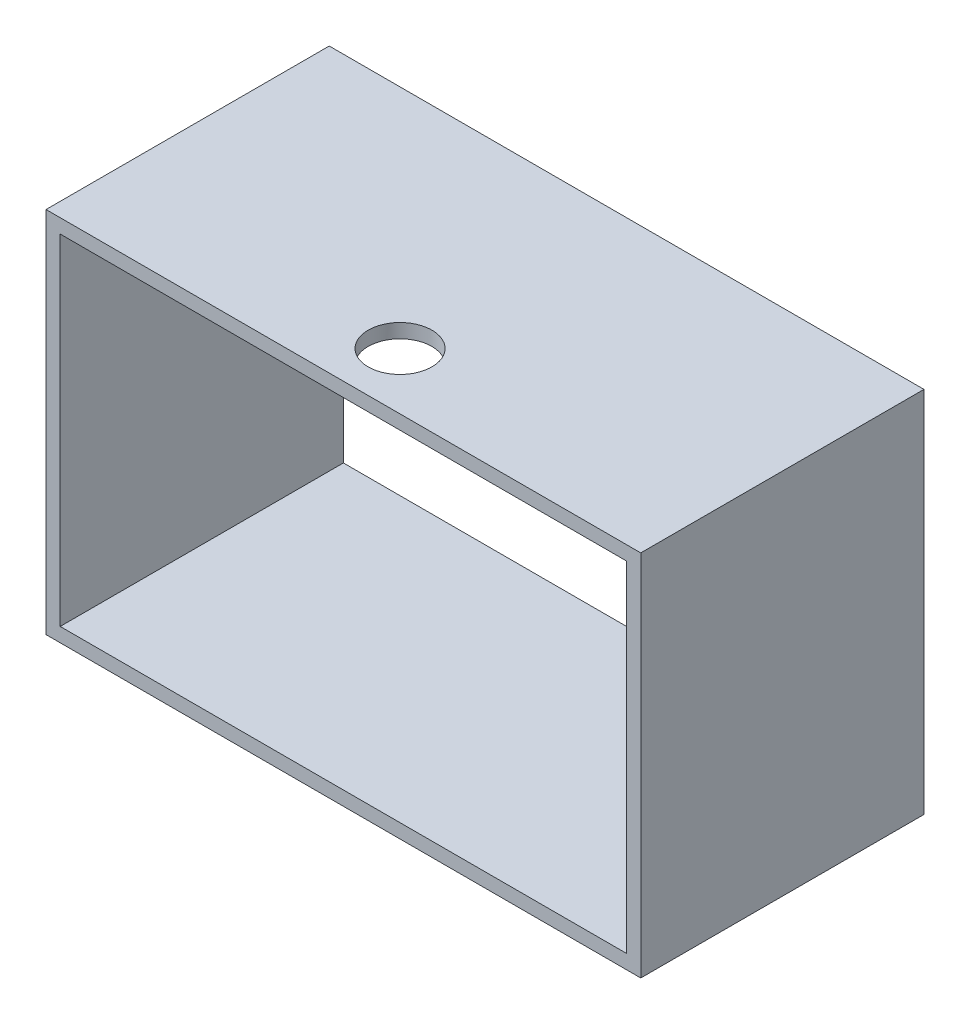
from build123d import *

# Parameters (mm, degrees)
SKETCH1_W           = 266.7
SKETCH1_H           = 165.1
SKETCH1_W_2         = 254
SKETCH1_H_2         = 152.4
BOSS_EXTRUDE1_DEPTH = 215.9
SKETCH4_W           = 88.9
SKETCH4_H           = 165.1
CUT_EXTRUDE2_DEPTH  = 267.7
CUT_EXTRUDE3_REACH  = 167.1
SKETCH5_R           = 14.2875


with BuildPart() as part:
    # Sketch1 → Boss-Extrude1 (new body)
    with BuildSketch(Plane.XY):
        with Locations((133.35, 82.55)):
            Rectangle(SKETCH1_W, SKETCH1_H)
        with Locations((133.35, 82.55)):
            Rectangle(SKETCH1_W_2, SKETCH1_H_2, mode=Mode.SUBTRACT)
    extrude(amount=BOSS_EXTRUDE1_DEPTH)

    # Sketch4 → Cut-Extrude2 (cut, through all)
    with BuildSketch(Plane(origin=(266.7, 0, 0), x_dir=(0, 0, -1), z_dir=(1, 0, 0))):
        with Locations((-171.45, 82.55)):
            Rectangle(SKETCH4_W, SKETCH4_H)
    extrude(amount=-CUT_EXTRUDE2_DEPTH, mode=Mode.SUBTRACT)

    # Sketch5 → Cut-Extrude3 (cut, up to next)
    with BuildSketch(Plane(origin=(0, 165.1, 0), x_dir=(1, 0, 0), z_dir=(0, 1, 0)), mode=Mode.PRIVATE) as cut_extrude3_sk1:
        with Locations((133.35, -101.6)):
            Circle(SKETCH5_R)
    cut_extrude3_tool1 = extrude(cut_extrude3_sk1.sketch, amount=-CUT_EXTRUDE3_REACH, mode=Mode.PRIVATE) & part.part
    add(cut_extrude3_tool1.solids().sort_by_distance((133.35, 165.1, 101.6))[0], mode=Mode.SUBTRACT)


solid = part.part
